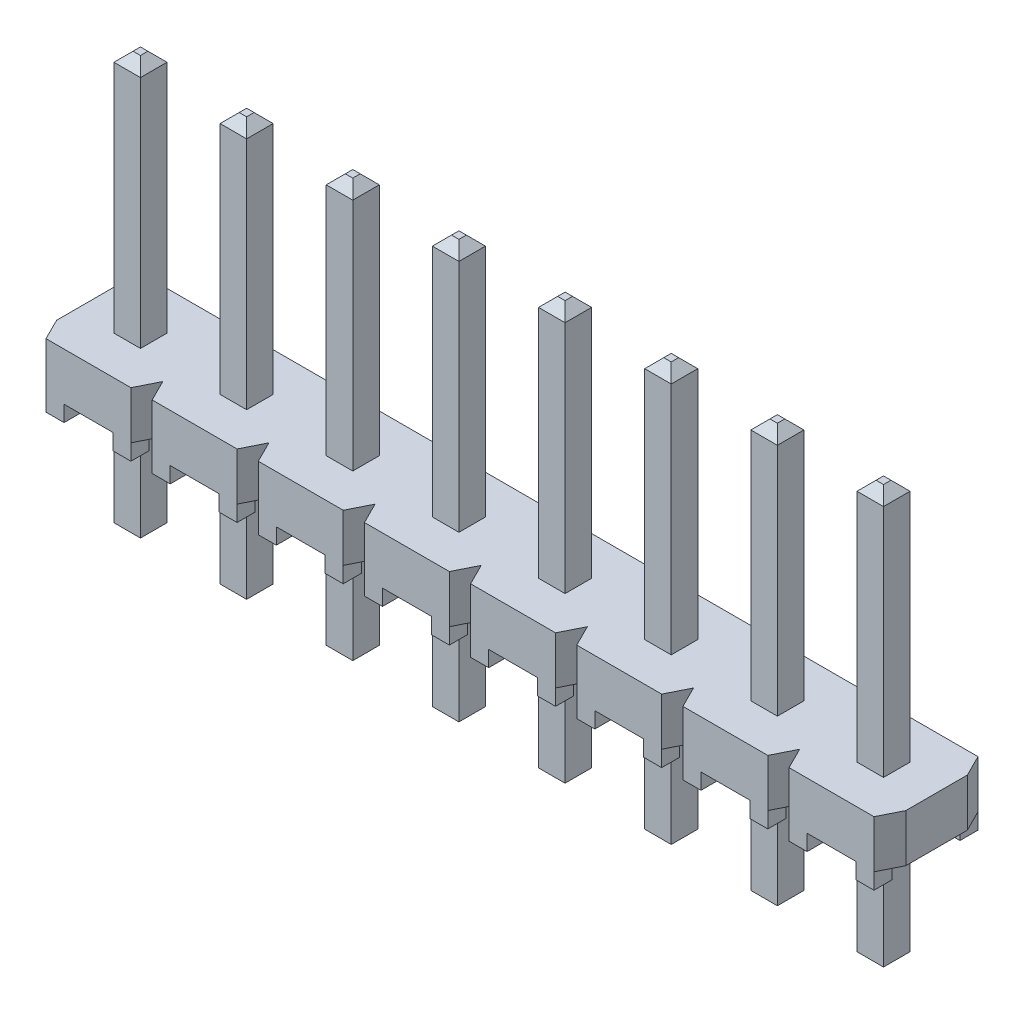
from build123d import *

# Parameters (mm, degrees)
SKETCH1_W                        = 20.32
SKETCH1_H                        = 2.4892
BASE_EXTRUDE_DEPTH               = 0.5715
SNAP_GROOVES_DEPTH               = 2.143
SKETCH4_W                        = 0.4318
SKETCH4_H                        = 0.4318
STANDOFFS_DEPTH                  = 0.381
POSITION_PATTERN_COUNT           = 8
POSITION_PATTERN_PITCH           = 2.54
SKETCH5_W                        = 0.635
SKETCH5_H                        = 10
TERMINAL_TH_DEPTH                = 0.3175
T1_TIP1_SIZE                     = 0.2286
TERMINAL_PATTERN_COUNT           = 8
TERMINAL_PATTERN_PITCH           = 2.54
T1_TIP1_OF_TERMINAL_PATTERN_SIZE = 0.2286


with BuildPart() as part:
    # Sketch1 → Base-Extrude (new body, symmetric)
    with BuildSketch(Plane(origin=(0, 0, 0), x_dir=(1, 0, 0), z_dir=(0, 1, 0))):
        Rectangle(SKETCH1_W, SKETCH1_H)
    extrude(amount=BASE_EXTRUDE_DEPTH, both=True)

    # Sketch3 → Snap Grooves (cut, through all)
    with BuildSketch(Plane(origin=(0, 0.5715, 0), x_dir=(-1, 0, 0), z_dir=(0, 1, 0))):
        Polygon((7.366, 1.2446), (7.874, 1.2446), (7.62, 0.7366), align=None)
        Polygon((7.366, -1.2446), (7.874, -1.2446), (7.62, -0.7366), align=None)
        Polygon((10.16, -0.7366), (10.414, -1.2446), (9.906, -1.2446), align=None)
        Polygon((10.16, 0.7366), (10.414, 1.2446), (9.906, 1.2446), align=None)
    snap_grooves = extrude(amount=-SNAP_GROOVES_DEPTH, mode=Mode.SUBTRACT)

    # Sketch4 → Standoffs (add)
    with BuildSketch(Plane.XZ.offset(0.5715)):
        with Locations((-9.6901, 1.0287)):
            Rectangle(SKETCH4_W, SKETCH4_H)
        with Locations((-8.0899, 1.0287)):
            Rectangle(SKETCH4_W, SKETCH4_H)
        with Locations((-8.0899, -1.0287)):
            Rectangle(SKETCH4_W, SKETCH4_H)
        with Locations((-9.6901, -1.0287)):
            Rectangle(SKETCH4_W, SKETCH4_H)
    standoffs = extrude(amount=STANDOFFS_DEPTH)

    # Position Pattern: Snap Grooves, Standoffs ×8
    with Locations(*[(i * POSITION_PATTERN_PITCH, 0, 0) for i in range(1, POSITION_PATTERN_COUNT)]):
        add(snap_grooves, mode=Mode.SUBTRACT)
        add(standoffs)

    # Sketch5 → Terminal -TH (add, symmetric)
    with BuildSketch(Plane.ZY.offset(8.89)):
        with Locations((0, 1.4135)):
            Rectangle(SKETCH5_W, SKETCH5_H)
    terminal_th = extrude(amount=TERMINAL_TH_DEPTH, both=True)

    # T1 Tip1
    t1_tip1_edges = [part.edges().sort_by_distance(p)[0] for p in [
        (-8.89, -3.5865, 0.3175),
        (-9.2075, -3.5865, 0),
        (-8.89, 6.4135, -0.3175),
        (-8.5725, -3.5865, 0),
        (-8.89, -3.5865, -0.3175),
        (-8.5725, 6.4135, 0),
        (-8.89, 6.4135, 0.3175),
        (-9.2075, 6.4135, 0),
    ]]
    chamfer(t1_tip1_edges, length=T1_TIP1_SIZE)

    # Terminal Pattern: Terminal -TH ×8
    with Locations(*[(i * TERMINAL_PATTERN_PITCH, 0, 0) for i in range(1, TERMINAL_PATTERN_COUNT)]):
        add(terminal_th)

    # T1 Tip1 of Terminal Pattern
    t1_tip1_of_terminal_pattern_edges = [part.edges().sort_by_distance(p)[0] for p in [
        (-6.35, -3.5865, 0.3175),
        (-6.6675, -3.5865, 0),
        (-6.35, 6.4135, -0.3175),
        (-6.0325, -3.5865, 0),
        (-6.35, -3.5865, -0.3175),
        (-6.0325, 6.4135, 0),
        (-6.35, 6.4135, 0.3175),
        (-6.6675, 6.4135, 0),
        (-3.81, -3.5865, 0.3175),
        (-4.1275, -3.5865, 0),
        (-3.81, 6.4135, -0.3175),
        (-3.4925, -3.5865, 0),
        (-3.81, -3.5865, -0.3175),
        (-3.4925, 6.4135, 0),
        (-3.81, 6.4135, 0.3175),
        (-4.1275, 6.4135, 0),
        (-1.27, -3.5865, 0.3175),
        (-1.5875, -3.5865, 0),
        (-1.27, 6.4135, -0.3175),
        (-0.9525, -3.5865, 0),
        (-1.27, -3.5865, -0.3175),
        (-0.9525, 6.4135, 0),
        (-1.27, 6.4135, 0.3175),
        (-1.5875, 6.4135, 0),
        (1.27, -3.5865, 0.3175),
        (0.9525, -3.5865, 0),
        (1.27, 6.4135, -0.3175),
        (1.5875, -3.5865, 0),
        (1.27, -3.5865, -0.3175),
        (1.5875, 6.4135, 0),
        (1.27, 6.4135, 0.3175),
        (0.9525, 6.4135, 0),
        (3.81, -3.5865, 0.3175),
        (3.4925, -3.5865, 0),
        (3.81, 6.4135, -0.3175),
        (4.1275, -3.5865, 0),
        (3.81, -3.5865, -0.3175),
        (4.1275, 6.4135, 0),
        (3.81, 6.4135, 0.3175),
        (3.4925, 6.4135, 0),
        (6.35, -3.5865, 0.3175),
        (6.0325, -3.5865, 0),
        (6.35, 6.4135, -0.3175),
        (6.6675, -3.5865, 0),
        (6.35, -3.5865, -0.3175),
        (6.6675, 6.4135, 0),
        (6.35, 6.4135, 0.3175),
        (6.0325, 6.4135, 0),
        (8.89, -3.5865, 0.3175),
        (8.5725, -3.5865, 0),
        (8.89, 6.4135, -0.3175),
        (9.2075, -3.5865, 0),
        (8.89, -3.5865, -0.3175),
        (9.2075, 6.4135, 0),
        (8.89, 6.4135, 0.3175),
        (8.5725, 6.4135, 0),
    ]]
    chamfer(t1_tip1_of_terminal_pattern_edges, length=T1_TIP1_OF_TERMINAL_PATTERN_SIZE)


solid = part.part
